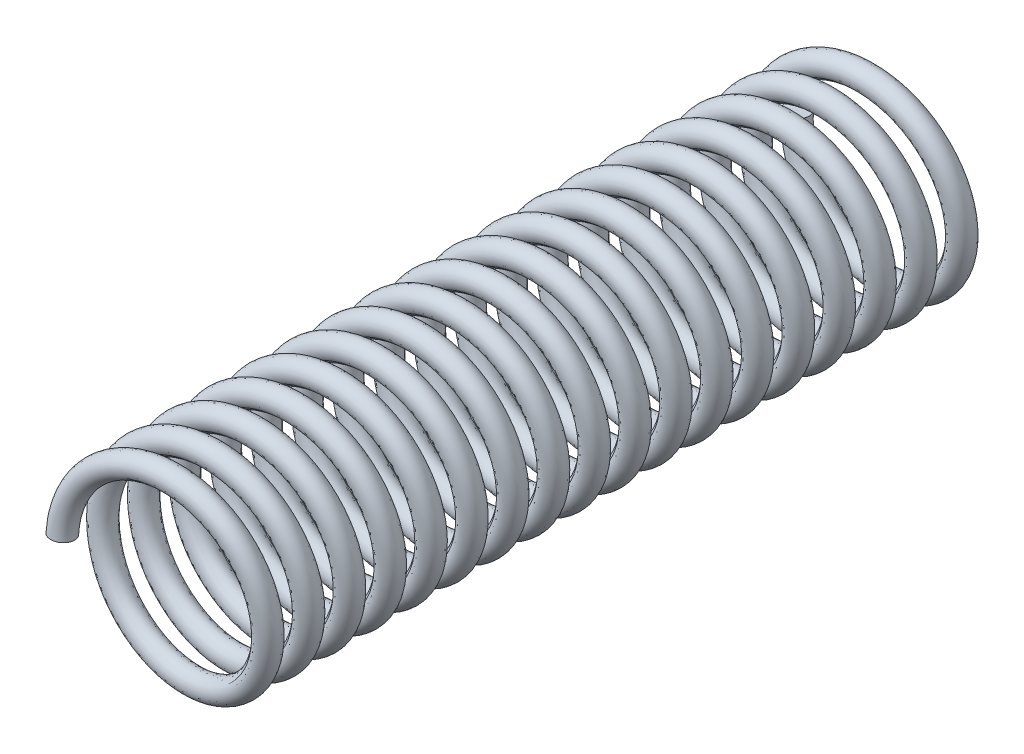
from build123d import *

# Parameters (mm, degrees)
SWEEP1_PITCH     = 0.883333333
SWEEP1_HEIGHT    = 15.9
SWEEP1_RADIUS    = 2
SWEEP1_PROFILE_R = 0.25


with BuildPart() as part:
    # Sweep1: sweep along a helix
    with BuildLine() as sweep1_path:
        Helix(SWEEP1_PITCH, SWEEP1_HEIGHT, SWEEP1_RADIUS, center=(0, 0, 0), direction=(0, 0, -1))
    # Sweep1 profile (on start of the path) → Sweep1 (sweep)
    with BuildSketch(Plane(origin=(-2, 0, 0), x_dir=(0, 0.070120408, 0.997538535), z_dir=(0, 0.997538535, -0.070120408))):
        Circle(SWEEP1_PROFILE_R)
    sweep(path=sweep1_path.line, is_frenet=True)


solid = part.part
